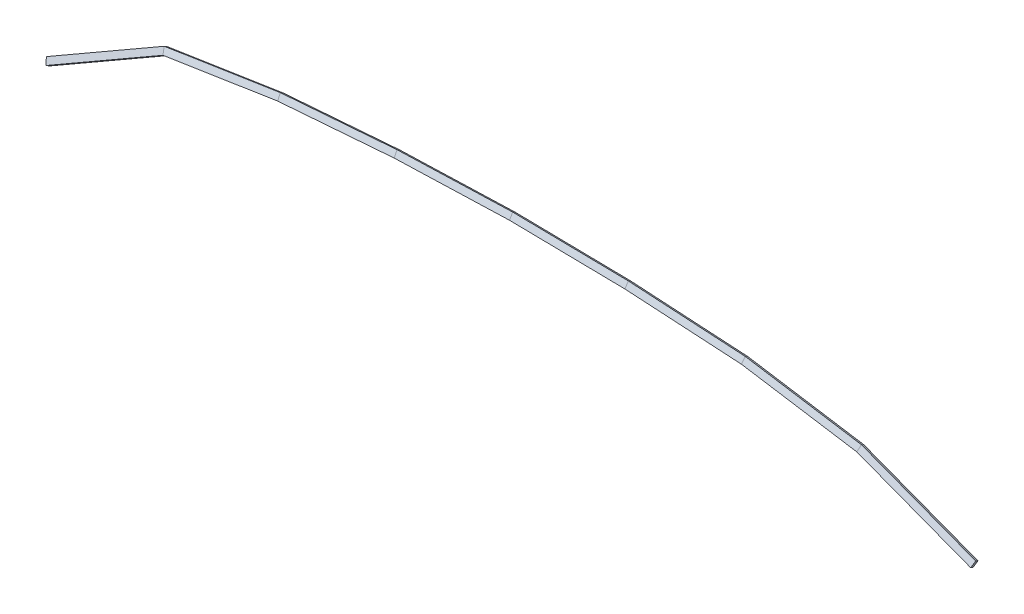
from build123d import *


with BuildPart() as part:
    # Sweep1: sweep along a path in Sketch1
    with BuildLine(Plane.XY.offset(133.35)) as sweep1_path:
        Line((-784.071645386, -162.117385896), (-591.554631016, -51.243460213))
        Line((-591.554631016, -51.243460213), (-402.166018744, -22.095582214))
        Line((-402.166018744, -22.095582214), (-211.416027506, -7.512293336))
        Line((-211.416027506, -7.512293336), (-22.665229034, -1.270332507))
        Line((-22.665229034, -1.270332507), (166.165138103, -4.260913688))
        Line((166.165138103, -4.260913688), (357.125134769, -15.536328702))
        Line((357.125134769, -15.536328702), (546.775185731, -45.538131397))
        Line((546.775185731, -45.538131397), (733.483443068, -116.654162228))
    # Sketch2 → Sweep1 (sweep)
    with BuildSketch(Plane(origin=(0, 0, 0), x_dir=(0, 0, -1), z_dir=(1, 0, 0))):
        Polygon((-133.35, -1.638900587), (-128.752617541, -4.293200587), (-133.934217541, -13.267995051), (-138.5316, -10.613695051), align=None)
    sweep(path=sweep1_path.line, transition=Transition.RIGHT)


solid = part.part
